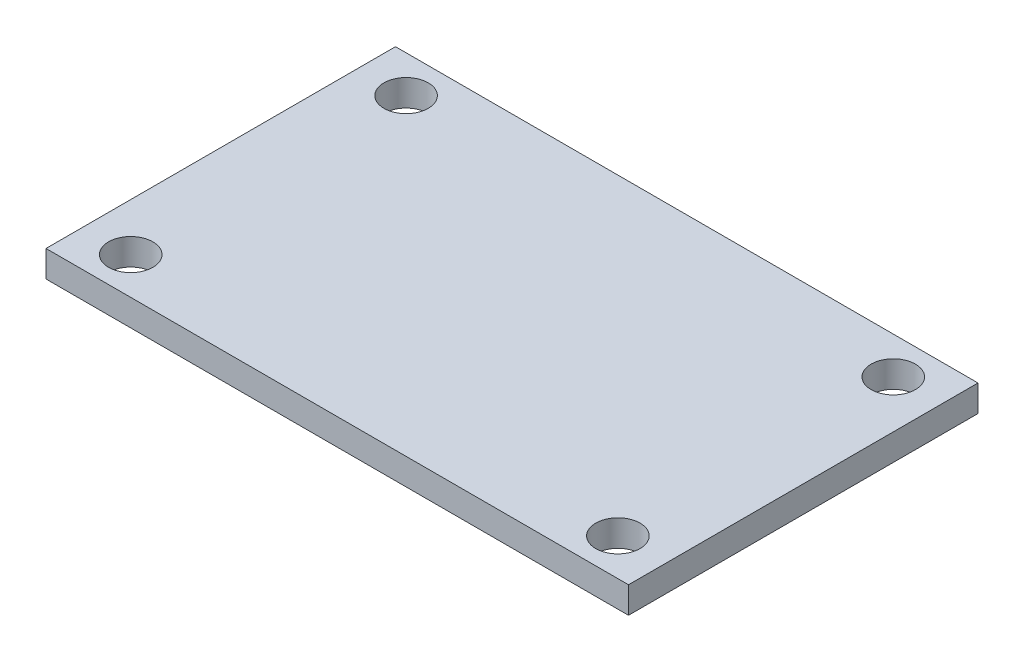
from build123d import *

# Parameters (mm, degrees)
SKETCH1_W                            = 69.85
SKETCH1_H                            = 41.91
BOSS_EXTRUDE1_DEPTH                  = 3.175
F_SIZE_BIT_1_4_CLEARANCE_HOLE1_D     = 5.3086
F_SIZE_BIT_1_4_CLEARANCE_HOLE1_DEPTH = 12.7
F_SIZE_BIT_1_4_CLEARANCE_HOLE1_TIP   = 1.594864341
LPATTERN2_COUNT                      = 2
LPATTERN2_PITCH                      = 43.18
LPATTERN2_COUNT_DIR2                 = 2
LPATTERN2_PITCH_DIR2                 = 34.29


with BuildPart() as part:
    # Sketch1 → Boss-Extrude1 (new body)
    with BuildSketch(Plane(origin=(0, 0, 0), x_dir=(1, 0, 0), z_dir=(0, 1, 0))):
        with Locations((-7.843619051, 1.300163759)):
            Rectangle(SKETCH1_W, SKETCH1_H)
    extrude(amount=BOSS_EXTRUDE1_DEPTH)

    # F size bit 1/4 Clearance Hole1
    with Locations(Plane(origin=(0, 3.175, 0), x_dir=(-1, 0, 0), z_dir=(0, 1, 0))):
        with Locations((37.053619051, 15.209836241), (-21.366380949, 15.209836241), (-21.366380949, -17.810163759), (37.053619051, -17.810163759)):
            Hole(F_SIZE_BIT_1_4_CLEARANCE_HOLE1_D / 2, depth=F_SIZE_BIT_1_4_CLEARANCE_HOLE1_DEPTH)
            with Locations((0, 0, -(F_SIZE_BIT_1_4_CLEARANCE_HOLE1_DEPTH + F_SIZE_BIT_1_4_CLEARANCE_HOLE1_TIP / 2))):  # 118° drill point
                Cone(0, F_SIZE_BIT_1_4_CLEARANCE_HOLE1_D / 2, F_SIZE_BIT_1_4_CLEARANCE_HOLE1_TIP, mode=Mode.SUBTRACT)

    # Sketch14 → Tap Drill for M3x0.5 Tap1 (revolve, cut)
    with BuildSketch(Plane(origin=(-29.433619051, 0, 15.844836241), x_dir=(0, 0, -1), z_dir=(1, 0, 0))):
        Polygon((0, 0), (0, 3.037075774), (1.25, 2.286), (1.25, 0), align=None)
    tap_drill_for_m3x0_5_tap1 = revolve(axis=Axis((-29.433619051, -6.35, 15.844836241), (0, 1, 0)), mode=Mode.SUBTRACT)

    # LPattern2: Tap Drill for M3x0.5 Tap1 2 × 2
    with Locations(*[(i * LPATTERN2_PITCH, 0, -j * LPATTERN2_PITCH_DIR2) for i in range(LPATTERN2_COUNT) for j in range(LPATTERN2_COUNT_DIR2) if (i, j) != (0, 0)]):
        add(tap_drill_for_m3x0_5_tap1, mode=Mode.SUBTRACT)


solid = part.part
